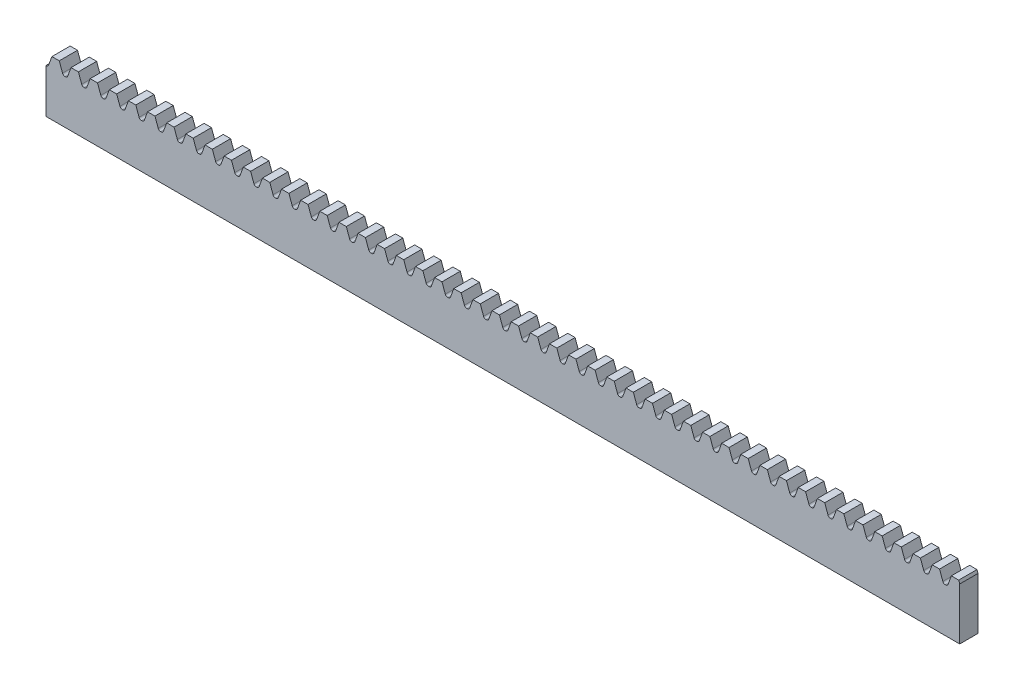
from build123d import *

# Parameters (mm, degrees)
SKETCH1_W           = 150
SKETCH1_H           = 9
BOSS_EXTRUDE1_DEPTH = 1.5
CUT_EXTRUDE1_DEPTH  = 4
LPATTERN1_COUNT     = 49
LPATTERN1_PITCH     = 3.1416


with BuildPart() as part:
    # Sketch1 → Boss-Extrude1 (new body, symmetric)
    with BuildSketch(Plane.XY):
        with Locations((75, 4.5)):
            Rectangle(SKETCH1_W, SKETCH1_H)
    extrude(amount=BOSS_EXTRUDE1_DEPTH, both=True)

    # Sketch2 → Cut-Extrude1 (cut, through all)
    with BuildSketch(Plane.XY.offset(1.5)):
        with BuildLine():
            Line((-0.967383281, 9), (0.967383281, 9))
            Line((0.967383281, 9), (0.426229404, 7.513191943))
            ThreePointArc((0.426229404, 7.513191943), (0.27978293, 7.322339182), (0.050352355, 7.25))
            Line((0.050352355, 7.25), (-0.050352355, 7.25))
            ThreePointArc((-0.050352355, 7.25), (-0.27978293, 7.322339182), (-0.426229404, 7.513191943))
            Line((-0.426229404, 7.513191943), (-0.967383281, 9))
        make_face()
    cut_extrude1 = extrude(amount=-CUT_EXTRUDE1_DEPTH, mode=Mode.SUBTRACT)

    # LPattern1: Cut-Extrude1 ×49
    with Locations(*[(i * LPATTERN1_PITCH, 0, 0) for i in range(1, LPATTERN1_COUNT)]):
        add(cut_extrude1, mode=Mode.SUBTRACT)


solid = part.part
